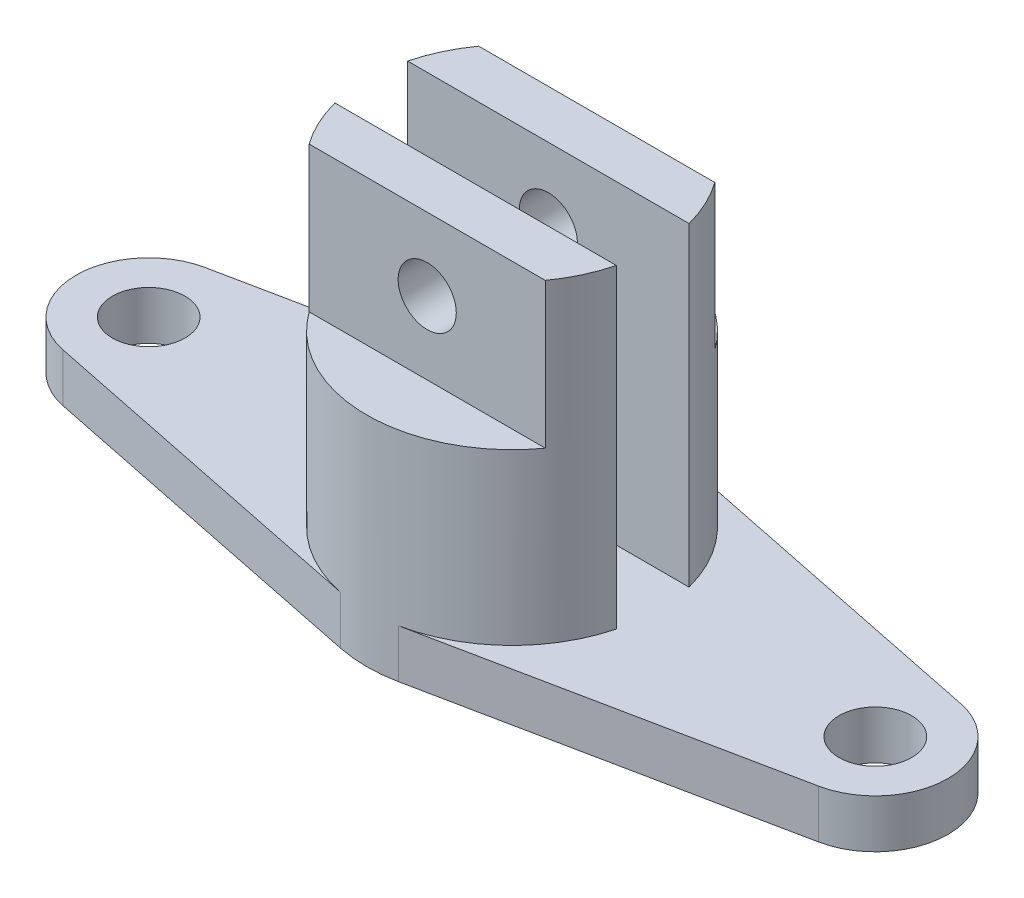
from build123d import *

# Parameters (mm, degrees)
BOSS_EXTRUDE1_DEPTH   = 1905
BOSS_EXTRUDE1_2_DEPTH = 1905
BOSS_EXTRUDE2_DEPTH   = 1143
SKETCH3_4_R           = 190.5
BOSS_EXTRUDE3_DEPTH   = 254
SKETCH4_R             = 152.4
CUT_EXTRUDE1_DEPTH    = 1264.92


with BuildPart() as part:
    # Sketch3 → Boss-Extrude1 (new body)
    with BuildSketch(Plane(origin=(0, 0, 0), x_dir=(1, 0, 0), z_dir=(0, 1, 0))):
        with BuildLine():
            Line((618.921440895, 444.5), (-618.921440895, 444.5))
            ThreePointArc((-618.921440895, 444.5), (-690.148190074, 323.016215905), (-737.803327453, 190.5))
            Line((-737.803327453, 190.5), (737.803327453, 190.5))
            ThreePointArc((737.803327453, 190.5), (690.148190074, 323.016215905), (618.921440895, 444.5))
        make_face()
    extrude(amount=BOSS_EXTRUDE1_DEPTH)



with BuildPart() as body_2:
    # Sketch3 → Boss-Extrude1 2 (new body)
    with BuildSketch(Plane(origin=(0, 0, 0), x_dir=(1, 0, 0), z_dir=(0, 1, 0))):
        with BuildLine():
            ThreePointArc((-737.803327453, -190.5), (-690.148190074, -323.016215905), (-618.921440895, -444.5))
            Line((-618.921440895, -444.5), (618.921440895, -444.5))
            ThreePointArc((618.921440895, -444.5), (690.148190074, -323.016215905), (737.803327453, -190.5))
            Line((737.803327453, -190.5), (-737.803327453, -190.5))
        make_face()
    extrude(amount=BOSS_EXTRUDE1_2_DEPTH)


with BuildPart() as part_1:
    add(part.part)

    add(body_2.part)  # Boss-Extrude2 merges body 2
    # Sketch3_3 → Boss-Extrude2 (add)
    with BuildSketch(Plane(origin=(0, 0, 0), x_dir=(1, 0, 0), z_dir=(0, 1, 0))):
        with BuildLine():
            ThreePointArc((618.921440895, 444.5), (0, 762), (-618.921440895, 444.5))
            Line((-618.921440895, 444.5), (618.921440895, 444.5))
        make_face()
        with BuildLine():
            ThreePointArc((-618.921440895, -444.5), (0, -762), (618.921440895, -444.5))
            Line((618.921440895, -444.5), (-618.921440895, -444.5))
        make_face()
    extrude(amount=BOSS_EXTRUDE2_DEPTH)

    # Sketch3_4 → Boss-Extrude3 (add)
    with BuildSketch(Plane(origin=(0, 0, 0), x_dir=(1, 0, 0), z_dir=(0, 1, 0))):
        with BuildLine():
            ThreePointArc((-618.921440895, 444.5), (-414.187118992, 639.603807416), (-152.4, 746.6044736))
            Line((-152.4, 746.6044736), (-1981.2, 373.3022368))
            ThreePointArc((-1981.2, 373.3022368), (-2286, 0), (-1981.2, -373.3022368))
            Line((-1981.2, -373.3022368), (-152.4, -746.6044736))
            ThreePointArc((-152.4, -746.6044736), (-414.187118992, -639.603807416), (-618.921440895, -444.5))
            ThreePointArc((-618.921440895, -444.5), (-690.148190074, -323.016215905), (-737.803327453, -190.5))
            Line((-737.803327453, -190.5), (737.803327453, -190.5))
            ThreePointArc((737.803327453, -190.5), (690.148190074, -323.016215905), (618.921440895, -444.5))
            ThreePointArc((618.921440895, -444.5), (414.187118992, -639.603807416), (152.4, -746.6044736))
            Line((152.4, -746.6044736), (1981.2, -373.3022368))
            ThreePointArc((1981.2, -373.3022368), (2286, 0), (1981.2, 373.3022368))
            Line((1981.2, 373.3022368), (152.4, 746.6044736))
            ThreePointArc((152.4, 746.6044736), (414.187118992, 639.603807416), (618.921440895, 444.5))
            ThreePointArc((618.921440895, 444.5), (690.148190074, 323.016215905), (737.803327453, 190.5))
            Line((737.803327453, 190.5), (-737.803327453, 190.5))
            ThreePointArc((-737.803327453, 190.5), (-690.148190074, 323.016215905), (-618.921440895, 444.5))
        make_face()
        with Locations((-1905, 0)):
            Circle(SKETCH3_4_R, mode=Mode.SUBTRACT)
        with Locations((1905, 0)):
            Circle(SKETCH3_4_R, mode=Mode.SUBTRACT)
    extrude(amount=BOSS_EXTRUDE3_DEPTH)

    # Sketch4 → Cut-Extrude1 (cut)
    with BuildSketch(Plane.XY.offset(444.5)):
        with Locations((0, 1524)):
            Circle(SKETCH4_R)
    extrude(amount=-CUT_EXTRUDE1_DEPTH, mode=Mode.SUBTRACT)


solid = part_1.part
